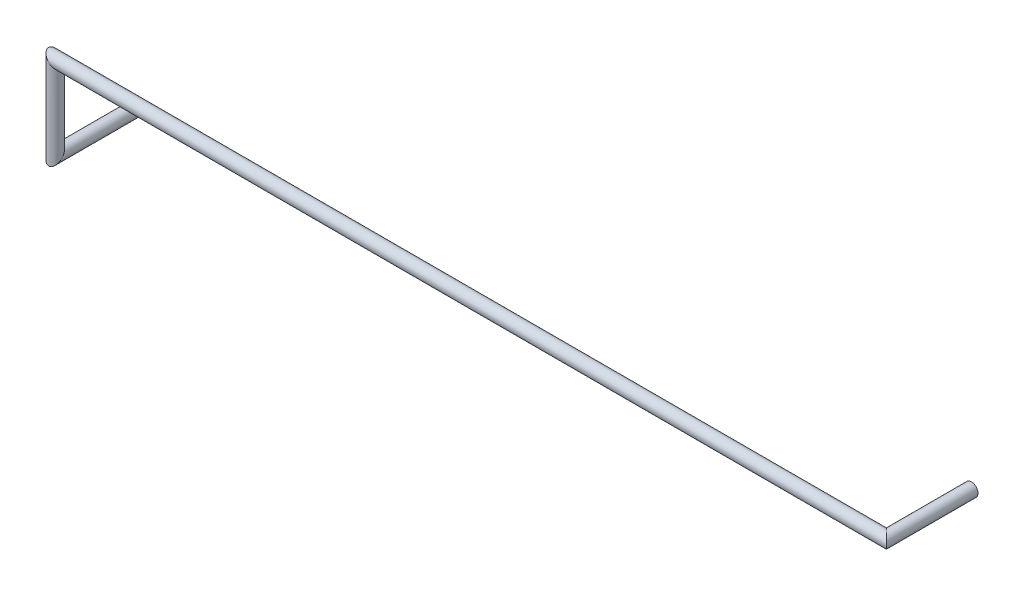
from build123d import *

# Parameters (mm, degrees)
SWEEP1_PROFILE_R = 0.2


with BuildPart() as part:
    # Sweep1: sweep along a curve in space
    with BuildLine() as sweep1_path:
        Line((0, 0, 0), (0, 0, 2.6))
        Line((0, 0, 2.6), (0, 2.54, 2.6))
        Line((0, 2.54, 2.6), (25.4, 2.54, 2.6))
        Line((25.4, 2.54, 2.6), (25.4, 2.54, 0))
    # Sweep1 profile (on start of the path) → Sweep1 (sweep)
    with BuildSketch(Plane.XY):
        Circle(SWEEP1_PROFILE_R)
    sweep(path=sweep1_path.line, transition=Transition.RIGHT)


solid = part.part
